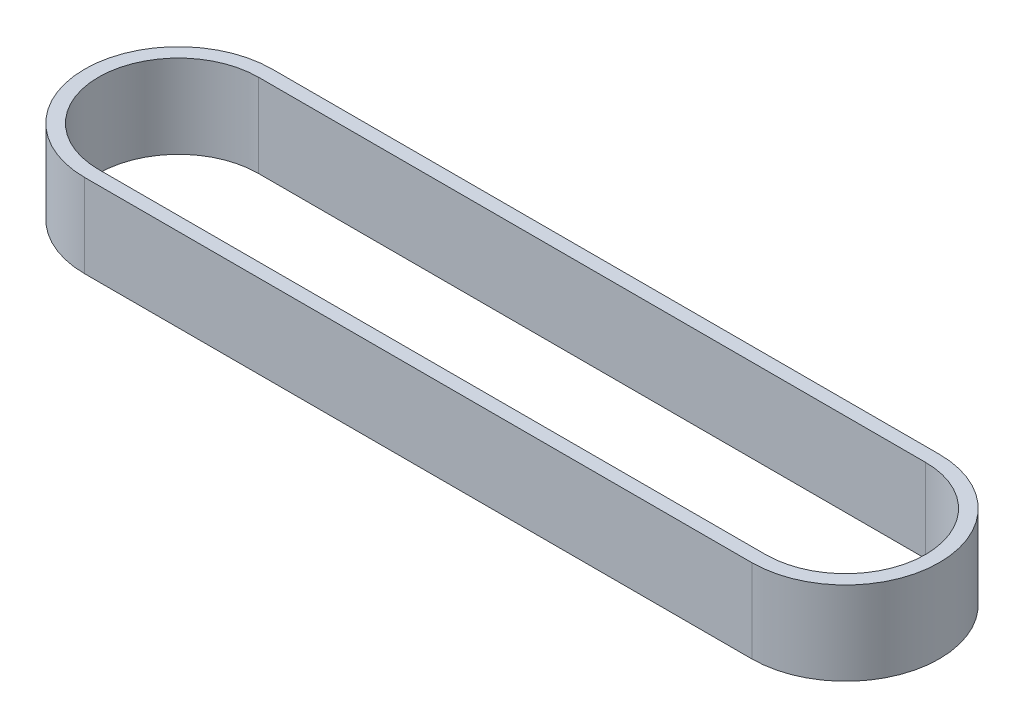
from build123d import *

# Parameters (mm, degrees)
BOSS_EXTRUDE1_DEPTH = 6


with BuildPart() as part:
    # Sketch1 → Boss-Extrude1 (new body)
    with BuildSketch(Plane(origin=(0, 0, 0), x_dir=(1, 0, 0), z_dir=(0, 1, 0))):
        with BuildLine():
            Line((0, 6.75), (48, 6.75))
            ThreePointArc((48, 6.75), (54.75, 0), (48, -6.75))
            Line((48, -6.75), (0, -6.75))
            ThreePointArc((0, -6.75), (-6.75, 0), (0, 6.75))
        make_face()
        with BuildLine():
            Line((0, 5.75), (48, 5.75))
            ThreePointArc((48, 5.75), (53.75, 0), (48, -5.75))
            Line((48, -5.75), (0, -5.75))
            ThreePointArc((0, -5.75), (-5.75, 0), (0, 5.75))
        make_face(mode=Mode.SUBTRACT)
    extrude(amount=BOSS_EXTRUDE1_DEPTH)


solid = part.part
